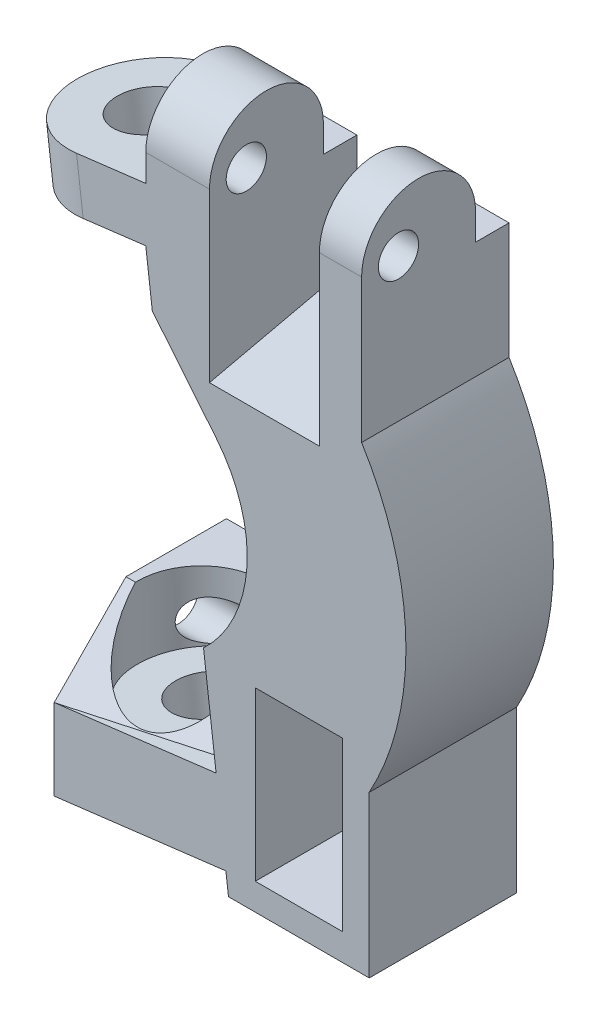
from build123d import *

# Parameters (mm, degrees)
SKETCH1_W                  = 6.5
SKETCH1_H                  = 12.5
MAIN_BASE_DEPTH            = 11
TOP_LINK_HOLES_DEPTH       = 16.1
STEERING_MOUNT_BOSS_DEPTH  = 4
CUT_FOR_LINK_DEPTH         = 4.1
BOSS_EXTRUDE6_REACH        = 28.238
SKETCH4_R                  = 2.5
STEERING_MOUNT_HOLES_DEPTH = 41.847064
SKETCH13_R                 = 1.5
CUT_EXTRUDE8_DEPTH         = 15
CUT_EXTRUDE9_REACH         = 13.5
SKETCH14_R                 = 4.75
SKETCH15_R                 = 1.5
CUT_EXTRUDE10_DEPTH        = 16.1


with BuildPart() as part:
    # Sketch1 → Main Base (new body)
    with BuildSketch(Plane.XY):
        with BuildLine():
            Line((0, 0), (-10.5, 0))
            Line((-10.5, 0), (-10.693077779, 1.572492321))
            Line((-10.693077779, 1.572492321), (-23.5, 0))
            Line((-23.5, 0), (-23.5, 6.045058953))
            Line((-23.5, 6.045058953), (-11.42429384, 7.527769231))
            Line((-11.42429384, 7.527769231), (-12.359894337, 15.1476238))
            ThreePointArc((-12.359894337, 15.1476238), (-9.125383898, 21.988425282), (-11.433037505, 29.194905528))
            Line((-11.433037505, 29.194905528), (-16.182087698, 34.999776092))
            Line((-16.182087698, 34.999776092), (-16.669565072, 38.969960698))
            Line((-16.669565072, 38.969960698), (-21.343327687, 38.396094808))
            Line((-21.343327687, 38.396094808), (-21.83080506, 42.366279414))
            Line((-21.83080506, 42.366279414), (-16.669565072, 43))
            Line((-16.669565072, 43), (-0.569565072, 43))
            Line((-0.569565072, 43), (-0.569565072, 34.310888907))
            ThreePointArc((-0.569565072, 34.310888907), (2.730584507, 23.23242246), (0, 12))
            Line((0, 12), (0, 0))
        make_face()
        with Locations((-5.25, 8.25)):
            Rectangle(SKETCH1_W, SKETCH1_H, mode=Mode.SUBTRACT)
    extrude(amount=MAIN_BASE_DEPTH)

    # Sketch2 → Top Link Holes (add)
    with BuildSketch(Plane(origin=(-0.569565072, 0, 0), x_dir=(0, 0, -1), z_dir=(1, 0, 0))):
        with BuildLine():
            Line((-11, 43), (-11, 45))
            ThreePointArc((-11, 45), (-6.75, 49.25), (-2.5, 45))
            Line((-2.5, 45), (-2.5, 43))
            Line((-2.5, 43), (-11, 43))
        make_face()
    extrude(amount=-TOP_LINK_HOLES_DEPTH)

    # Sketch3 → Steering Mount Boss (add)
    with BuildSketch(Plane(origin=(-5.448899417, 44.377724505, 0), x_dir=(0.992546152, 0.121869343, 0), z_dir=(-0.121869343, 0.992546152, 0))):
        with BuildLine():
            Line((-16.504930895, 0), (-16.504930895, -11))
            ThreePointArc((-16.504930895, -11), (-22.004930895, -5.5), (-16.504930895, 0))
        make_face()
    extrude(amount=-STEERING_MOUNT_BOSS_DEPTH)

    # Sketch5 → Cut for Link (cut, symmetric)
    with BuildSketch(Plane(origin=(-7.819565072, 0, 0), x_dir=(0, 0, -1), z_dir=(1, 0, 0))):
        with BuildLine():
            Line((-11, 32.5), (0, 35))
            Line((0, 35), (0, 43))
            Line((0, 43), (-2.5, 43))
            Line((-2.5, 43), (-2.5, 45))
            ThreePointArc((-2.5, 45), (-6.75, 49.25), (-11, 45))
            Line((-11, 45), (-11, 32.5))
        make_face()
    extrude(amount=CUT_FOR_LINK_DEPTH, both=True, mode=Mode.SUBTRACT)

    # Boss-Extrude6: up to this face of the body (flat: up to its plane)
    boss_extrude6_end = Plane(part.part.faces().sort_by_distance((-11.892094088, 11.337696516, 5.5))[0])
    # Sketch12 → Boss-Extrude6 (add, up to the picked face)
    with BuildSketch(Plane.ZY.offset(23.5), mode=Mode.PRIVATE) as boss_extrude6_sk1:
        with BuildLine():
            Line((11, 6.045058953), (0, 6.045058953))
            Line((0, 6.045058953), (0, 4.853970757))
            ThreePointArc((0, 4.853970757), (-1.35322413, 6.175171241), (-1.85, 8))
            Line((-1.85, 8), (-1.85, 11.5))
            Line((-1.85, 11.5), (5.65, 11.5))
            Line((5.65, 11.5), (11, 6.045058953))
        make_face()
    boss_extrude6_tool1 = split(extrude(boss_extrude6_sk1.sketch, amount=-BOSS_EXTRUDE6_REACH, mode=Mode.PRIVATE), bisect_by=boss_extrude6_end, keep=Keep.BOTH, mode=Mode.PRIVATE)
    add(boss_extrude6_tool1.solids().sort_by_distance((-23.5, 8.500537, 3.327239))[0])

    # Sketch4 → Steering mount holes (cut)
    with BuildSketch(Plane(origin=(-5.448899417, 44.377724505, 0), x_dir=(0.992546152, 0.121869343, 0), z_dir=(-0.121869343, 0.992546152, 0))):
        with Locations((-16.504930895, -5.5)):
            Circle(SKETCH4_R)
    extrude(amount=-STEERING_MOUNT_HOLES_DEPTH, mode=Mode.SUBTRACT)

    # Sketch13 → Cut-Extrude8 (cut)
    with BuildSketch(Plane.ZY.offset(23.5)):
        with Locations((1.75, 8)):
            Circle(SKETCH13_R)
    extrude(amount=-CUT_EXTRUDE8_DEPTH, mode=Mode.SUBTRACT)

    # Cut-Extrude9: up to this face of the body (flat: up to its plane)
    cut_extrude9_end = Plane(part.part.faces().sort_by_distance((-15.449529226, 7.033532472, 10.515271267))[0])
    # Sketch14 → Cut-Extrude9 (cut, up to the picked face)
    with BuildSketch(Plane(origin=(0, 11.5, 0), x_dir=(1, 0, 0), z_dir=(0, 1, 0)), mode=Mode.PRIVATE) as cut_extrude9_sk1:
        with Locations((-18.040902496, -5.5)):
            Circle(SKETCH14_R)
    cut_extrude9_tool1 = split(extrude(cut_extrude9_sk1.sketch, amount=-CUT_EXTRUDE9_REACH, mode=Mode.PRIVATE), bisect_by=cut_extrude9_end, keep=Keep.BOTH, mode=Mode.PRIVATE)
    add(cut_extrude9_tool1.solids().sort_by_distance((-18.040902, 11.5, 5.5))[0], mode=Mode.SUBTRACT)

    # Sketch15 → Cut-Extrude10 (cut)
    with BuildSketch(Plane(origin=(-0.569565072, 0, 0), x_dir=(0, 0, -1), z_dir=(1, 0, 0))):
        with Locations((-8.25, 45)):
            Circle(SKETCH15_R)
    extrude(amount=-CUT_EXTRUDE10_DEPTH, mode=Mode.SUBTRACT)


solid = part.part
